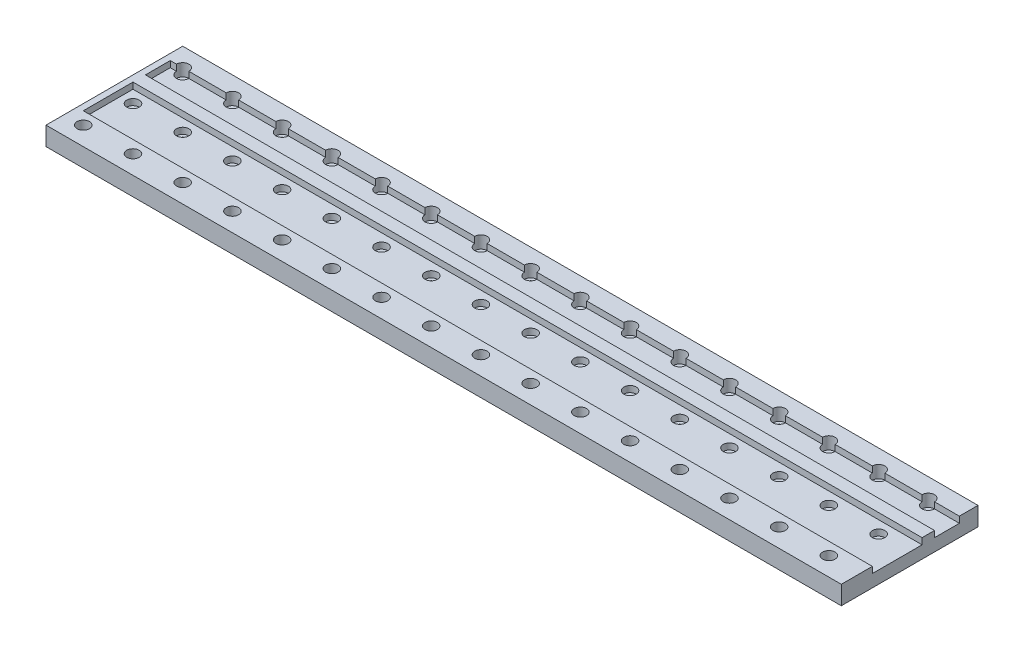
from build123d import *

# Parameters (mm, degrees)
SKETCH1_W           = 812.8
SKETCH1_H           = 139.7
BOSS_EXTRUDE1_DEPTH = 19.05
SKETCH2_W           = 806.45
SKETCH2_H           = 50.8
SKETCH2_H_2         = 25.4
CUT_EXTRUDE1_DEPTH  = 6.35
SKETCH3_R           = 6.35
CUT_EXTRUDE4_DEPTH  = 12.7
SKETCH4_R           = 2.8067
CUT_EXTRUDE5_DEPTH  = 6.35


with BuildPart() as part:
    # Sketch1 → Boss-Extrude1 (new body)
    with BuildSketch(Plane(origin=(0, 0, 0), x_dir=(1, 0, 0), z_dir=(0, 1, 0))):
        with Locations((406.4, 69.85)):
            Rectangle(SKETCH1_W, SKETCH1_H)
    extrude(amount=BOSS_EXTRUDE1_DEPTH)

    # Sketch2 → Cut-Extrude1 (cut)
    with BuildSketch(Plane(origin=(0, 19.05, 0), x_dir=(1, 0, 0), z_dir=(0, 1, 0))):
        with Locations((409.575, 57.15)):
            Rectangle(SKETCH2_W, SKETCH2_H)
        with Locations((409.575, 107.95)):
            Rectangle(SKETCH2_W, SKETCH2_H_2)
    extrude(amount=-CUT_EXTRUDE1_DEPTH, mode=Mode.SUBTRACT)

    # Sketch3 → Cut-Extrude4 (cut)
    with BuildSketch(Plane(origin=(0, 19.05, 0), x_dir=(1, 0, 0), z_dir=(0, 1, 0))):
        with Locations((19.05, 19.05)):
            Circle(SKETCH3_R)
        with Locations((19.05, 69.85)):
            Circle(SKETCH3_R)
        with Locations((19.05, 120.65)):
            Circle(SKETCH3_R)
        with Locations((69.85, 19.05)):
            Circle(SKETCH3_R)
        with Locations((69.85, 69.85)):
            Circle(SKETCH3_R)
        with Locations((69.85, 120.65)):
            Circle(SKETCH3_R)
        with Locations((120.65, 19.05)):
            Circle(SKETCH3_R)
        with Locations((120.65, 69.85)):
            Circle(SKETCH3_R)
        with Locations((120.65, 120.65)):
            Circle(SKETCH3_R)
        with Locations((171.45, 19.05)):
            Circle(SKETCH3_R)
        with Locations((171.45, 69.85)):
            Circle(SKETCH3_R)
        with Locations((171.45, 120.65)):
            Circle(SKETCH3_R)
        with Locations((222.25, 19.05)):
            Circle(SKETCH3_R)
        with Locations((222.25, 69.85)):
            Circle(SKETCH3_R)
        with Locations((222.25, 120.65)):
            Circle(SKETCH3_R)
        with Locations((273.05, 19.05)):
            Circle(SKETCH3_R)
        with Locations((273.05, 69.85)):
            Circle(SKETCH3_R)
        with Locations((273.05, 120.65)):
            Circle(SKETCH3_R)
        with Locations((323.85, 19.05)):
            Circle(SKETCH3_R)
        with Locations((323.85, 69.85)):
            Circle(SKETCH3_R)
        with Locations((323.85, 120.65)):
            Circle(SKETCH3_R)
        with Locations((374.65, 19.05)):
            Circle(SKETCH3_R)
        with Locations((374.65, 69.85)):
            Circle(SKETCH3_R)
        with Locations((374.65, 120.65)):
            Circle(SKETCH3_R)
        with Locations((425.45, 19.05)):
            Circle(SKETCH3_R)
        with Locations((425.45, 69.85)):
            Circle(SKETCH3_R)
        with Locations((425.45, 120.65)):
            Circle(SKETCH3_R)
        with Locations((476.25, 19.05)):
            Circle(SKETCH3_R)
        with Locations((476.25, 69.85)):
            Circle(SKETCH3_R)
        with Locations((476.25, 120.65)):
            Circle(SKETCH3_R)
        with Locations((527.05, 19.05)):
            Circle(SKETCH3_R)
        with Locations((527.05, 69.85)):
            Circle(SKETCH3_R)
        with Locations((527.05, 120.65)):
            Circle(SKETCH3_R)
        with Locations((577.85, 19.05)):
            Circle(SKETCH3_R)
        with Locations((577.85, 69.85)):
            Circle(SKETCH3_R)
        with Locations((577.85, 120.65)):
            Circle(SKETCH3_R)
        with Locations((628.65, 19.05)):
            Circle(SKETCH3_R)
        with Locations((628.65, 69.85)):
            Circle(SKETCH3_R)
        with Locations((628.65, 120.65)):
            Circle(SKETCH3_R)
        with Locations((679.45, 19.05)):
            Circle(SKETCH3_R)
        with Locations((679.45, 69.85)):
            Circle(SKETCH3_R)
        with Locations((679.45, 120.65)):
            Circle(SKETCH3_R)
        with Locations((730.25, 19.05)):
            Circle(SKETCH3_R)
        with Locations((730.25, 69.85)):
            Circle(SKETCH3_R)
        with Locations((730.25, 120.65)):
            Circle(SKETCH3_R)
        with Locations((781.05, 19.05)):
            Circle(SKETCH3_R)
        with Locations((781.05, 69.85)):
            Circle(SKETCH3_R)
        with Locations((781.05, 120.65)):
            Circle(SKETCH3_R)
    extrude(amount=-CUT_EXTRUDE4_DEPTH, mode=Mode.SUBTRACT)

    # Sketch4 → Cut-Extrude5 (cut)
    with BuildSketch(Plane(origin=(0, 6.35, 0), x_dir=(1, 0, 0), z_dir=(0, 1, 0))):
        with Locations((19.05, 19.05)):
            Circle(SKETCH4_R)
        with Locations((19.05, 69.85)):
            Circle(SKETCH4_R)
        with Locations((19.05, 120.65)):
            Circle(SKETCH4_R)
        with Locations((69.85, 19.05)):
            Circle(SKETCH4_R)
        with Locations((69.85, 69.85)):
            Circle(SKETCH4_R)
        with Locations((69.85, 120.65)):
            Circle(SKETCH4_R)
        with Locations((120.65, 19.05)):
            Circle(SKETCH4_R)
        with Locations((120.65, 69.85)):
            Circle(SKETCH4_R)
        with Locations((120.65, 120.65)):
            Circle(SKETCH4_R)
        with Locations((171.45, 19.05)):
            Circle(SKETCH4_R)
        with Locations((171.45, 69.85)):
            Circle(SKETCH4_R)
        with Locations((171.45, 120.65)):
            Circle(SKETCH4_R)
        with Locations((222.25, 19.05)):
            Circle(SKETCH4_R)
        with Locations((222.25, 69.85)):
            Circle(SKETCH4_R)
        with Locations((222.25, 120.65)):
            Circle(SKETCH4_R)
        with Locations((273.05, 19.05)):
            Circle(SKETCH4_R)
        with Locations((273.05, 69.85)):
            Circle(SKETCH4_R)
        with Locations((273.05, 120.65)):
            Circle(SKETCH4_R)
        with Locations((323.85, 19.05)):
            Circle(SKETCH4_R)
        with Locations((323.85, 69.85)):
            Circle(SKETCH4_R)
        with Locations((323.85, 120.65)):
            Circle(SKETCH4_R)
        with Locations((374.65, 19.05)):
            Circle(SKETCH4_R)
        with Locations((374.65, 69.85)):
            Circle(SKETCH4_R)
        with Locations((374.65, 120.65)):
            Circle(SKETCH4_R)
        with Locations((425.45, 19.05)):
            Circle(SKETCH4_R)
        with Locations((425.45, 69.85)):
            Circle(SKETCH4_R)
        with Locations((425.45, 120.65)):
            Circle(SKETCH4_R)
        with Locations((476.25, 19.05)):
            Circle(SKETCH4_R)
        with Locations((476.25, 69.85)):
            Circle(SKETCH4_R)
        with Locations((476.25, 120.65)):
            Circle(SKETCH4_R)
        with Locations((527.05, 19.05)):
            Circle(SKETCH4_R)
        with Locations((527.05, 69.85)):
            Circle(SKETCH4_R)
        with Locations((527.05, 120.65)):
            Circle(SKETCH4_R)
        with Locations((577.85, 19.05)):
            Circle(SKETCH4_R)
        with Locations((577.85, 69.85)):
            Circle(SKETCH4_R)
        with Locations((577.85, 120.65)):
            Circle(SKETCH4_R)
        with Locations((628.65, 19.05)):
            Circle(SKETCH4_R)
        with Locations((628.65, 69.85)):
            Circle(SKETCH4_R)
        with Locations((628.65, 120.65)):
            Circle(SKETCH4_R)
        with Locations((679.45, 19.05)):
            Circle(SKETCH4_R)
        with Locations((679.45, 69.85)):
            Circle(SKETCH4_R)
        with Locations((679.45, 120.65)):
            Circle(SKETCH4_R)
        with Locations((730.25, 19.05)):
            Circle(SKETCH4_R)
        with Locations((730.25, 69.85)):
            Circle(SKETCH4_R)
        with Locations((730.25, 120.65)):
            Circle(SKETCH4_R)
        with Locations((781.05, 19.05)):
            Circle(SKETCH4_R)
        with Locations((781.05, 69.85)):
            Circle(SKETCH4_R)
        with Locations((781.05, 120.65)):
            Circle(SKETCH4_R)
    extrude(amount=-CUT_EXTRUDE5_DEPTH, mode=Mode.SUBTRACT)


solid = part.part
